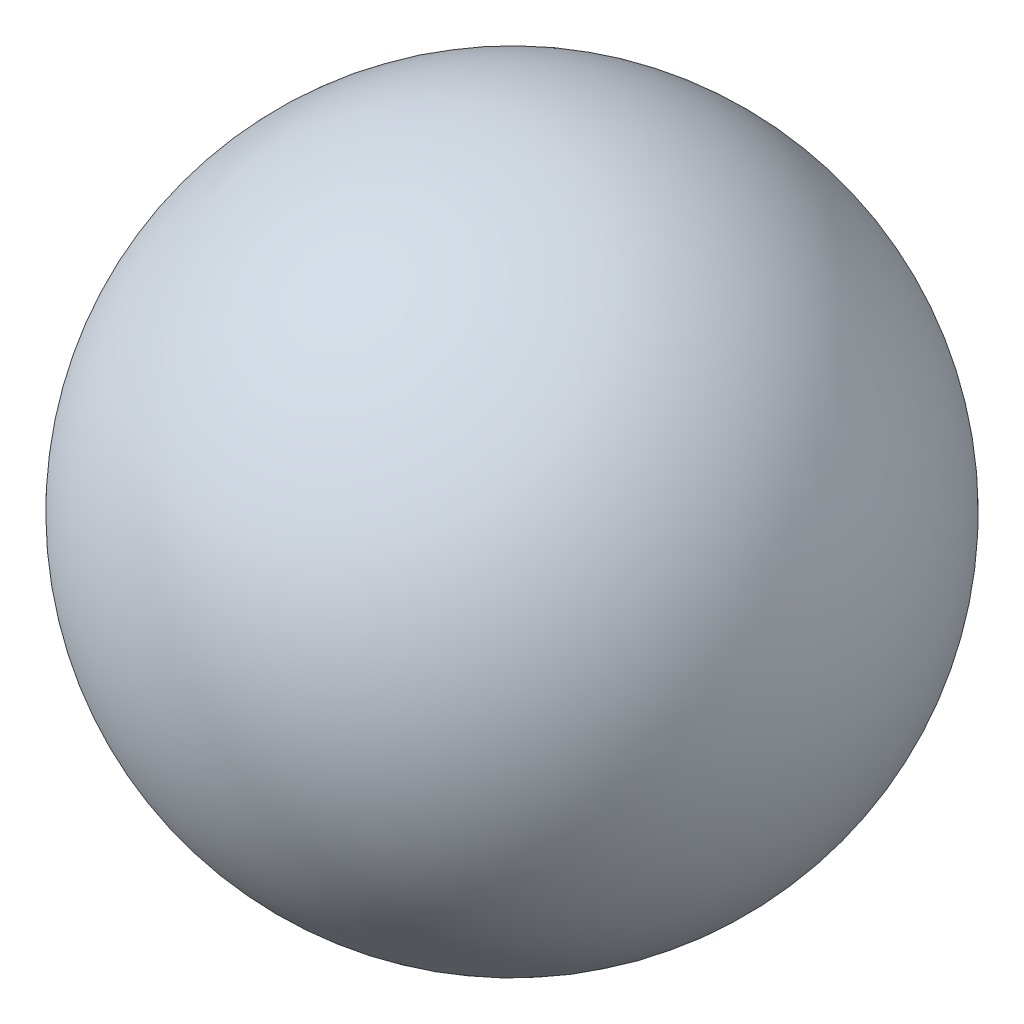
from build123d import *


with BuildPart() as part:
    # Sketch1 → Revolve4 (revolve)
    with BuildSketch(Plane(origin=(0, 0, 0), x_dir=(1, 0, 0), z_dir=(0, 1, 0))):
        with BuildLine():
            Line((-105.612676825, 17.163541982), (-227.26905777, -112.499733372))
            ThreePointArc((-227.26905777, -112.499733372), (-231.272504974, 13.160094777), (-105.612676825, 17.163541982))
        make_face()
    revolve(axis=Axis((-227.26905777, 0, 112.499733372), (0.684231614, 0, -0.729264766)))


solid = part.part
